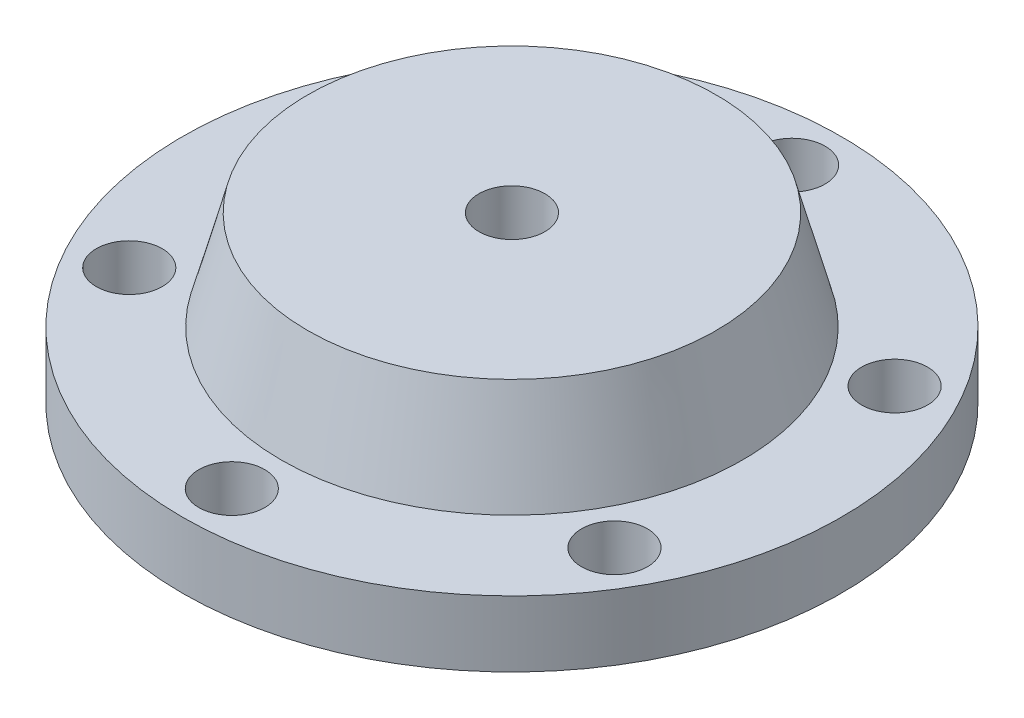
from build123d import *

# Parameters (mm, degrees)
SKETCH2_R           = 254
SKETCH2_R_2         = 25.4
BOSS_EXTRUDE2_DEPTH = 50.8
SKETCH3_R           = 177.8
BOSS_EXTRUDE3_DEPTH = 76.2
BOSS_EXTRUDE3_TAPER = 15
SKETCH4_R           = 25.4
CUT_EXTRUDE1_DEPTH  = 76.2


with BuildPart() as part:
    # Sketch2 → Boss-Extrude2 (new body)
    with BuildSketch(Plane(origin=(0, 0, 0), x_dir=(1, 0, 0), z_dir=(0, 1, 0))):
        Circle(SKETCH2_R)
        with Locations((0, 215.9)):
            Circle(SKETCH2_R_2, mode=Mode.SUBTRACT)
        with Locations((186.974884677, 107.95)):
            Circle(SKETCH2_R_2, mode=Mode.SUBTRACT)
        with Locations((186.974884677, -107.95)):
            Circle(SKETCH2_R_2, mode=Mode.SUBTRACT)
        with Locations((0, -215.9)):
            Circle(SKETCH2_R_2, mode=Mode.SUBTRACT)
        with Locations((-186.974884677, -107.95)):
            Circle(SKETCH2_R_2, mode=Mode.SUBTRACT)
        with Locations((-186.974884677, 107.95)):
            Circle(SKETCH2_R_2, mode=Mode.SUBTRACT)
    extrude(amount=BOSS_EXTRUDE2_DEPTH)

    # Sketch3 → Boss-Extrude3 (add)
    with BuildSketch(Plane(origin=(0, 50.8, 0), x_dir=(1, 0, 0), z_dir=(0, 1, 0))):
        Circle(SKETCH3_R)
    extrude(amount=BOSS_EXTRUDE3_DEPTH, taper=BOSS_EXTRUDE3_TAPER)

    # Sketch4 → Cut-Extrude1 (cut)
    with BuildSketch(Plane(origin=(0, 127, 0), x_dir=(1, 0, 0), z_dir=(0, 1, 0))):
        Circle(SKETCH4_R)
    extrude(amount=-CUT_EXTRUDE1_DEPTH, mode=Mode.SUBTRACT)


solid = part.part
